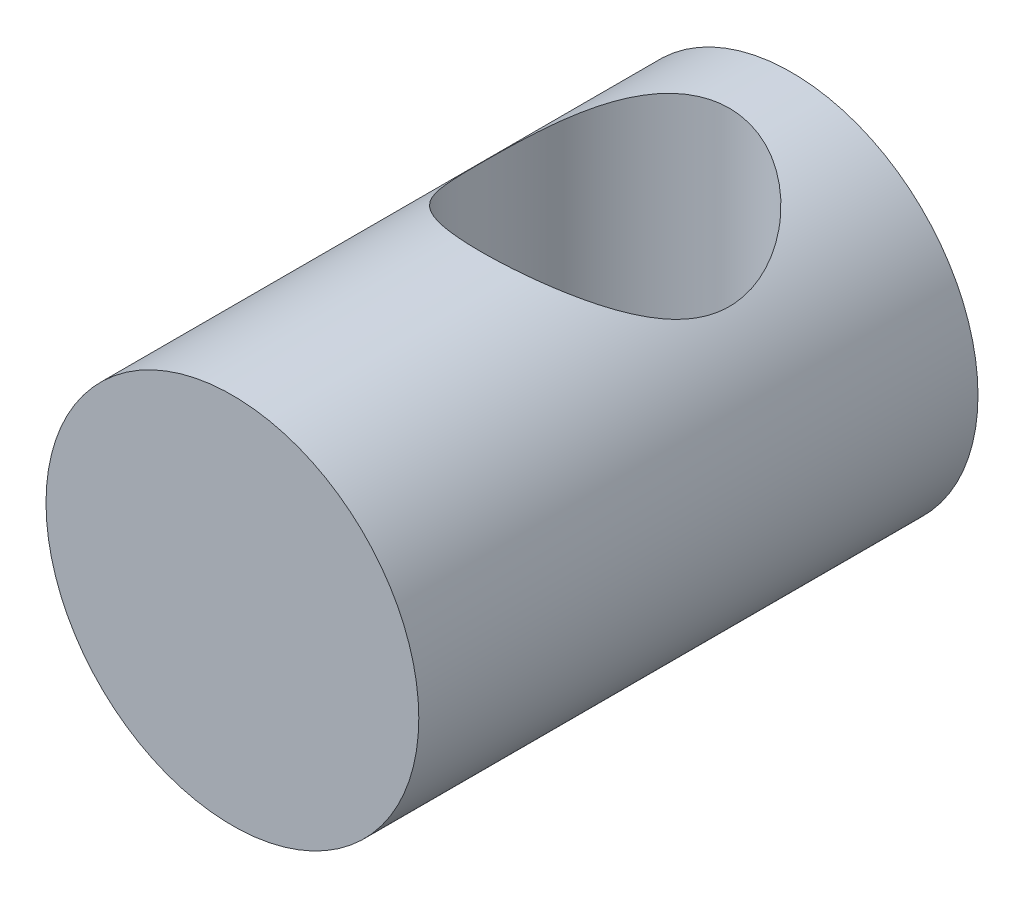
from build123d import *

# Parameters (mm, degrees)
SKETCH1_R           = 4.7625
BOSS_EXTRUDE1_DEPTH = 14.2875
SKETCH2_R           = 3.175
CUT_EXTRUDE1_DEPTH  = 7.14375


with BuildPart() as part:
    # Sketch1 → Boss-Extrude1 (new body)
    with BuildSketch(Plane.XY):
        Circle(SKETCH1_R)
    extrude(amount=-BOSS_EXTRUDE1_DEPTH)

    # Sketch2 → Cut-Extrude1 (cut, symmetric)
    with BuildSketch(Plane(origin=(0, 0, 0), x_dir=(1, 0, 0), z_dir=(0, 1, 0))):
        with Locations((0, 9.525)):
            Circle(SKETCH2_R)
    extrude(amount=CUT_EXTRUDE1_DEPTH, both=True, mode=Mode.SUBTRACT)


solid = part.part
